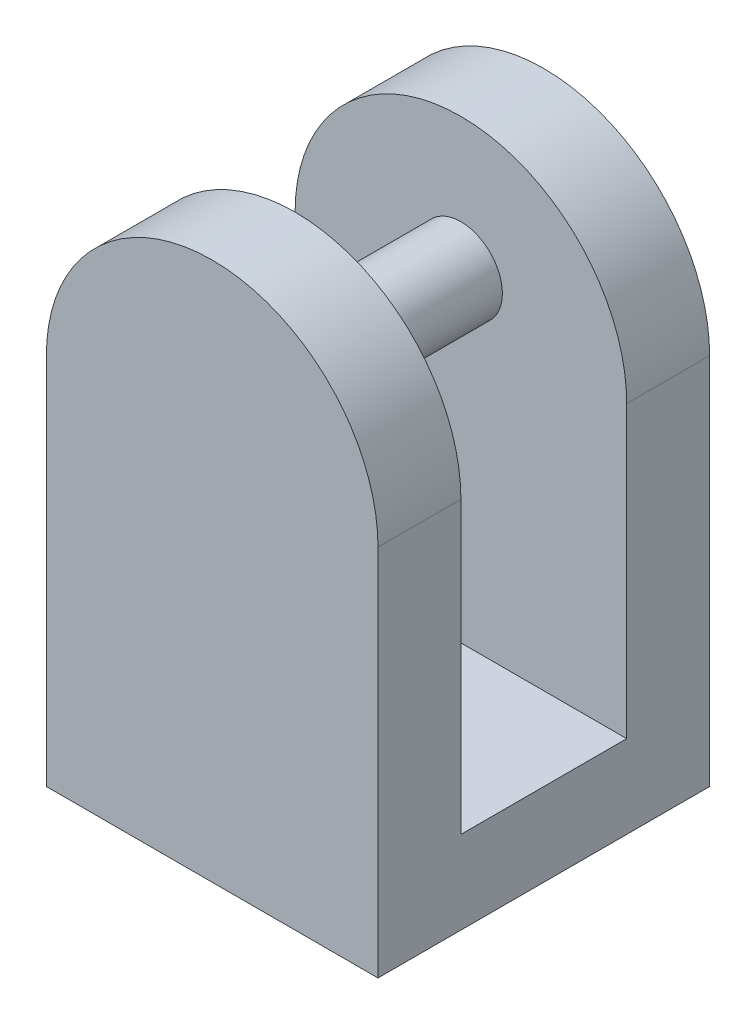
from build123d import *

# Parameters (mm, degrees)
BOSS_EXTRUDE1_DEPTH = 10
SKETCH3_W           = 20
SKETCH3_H           = 10
CUT_EXTRUDE2_DEPTH  = 27.5
SKETCH4_R           = 2.5
BOSS_EXTRUDE2_DEPTH = 10
SKETCH5_R           = 1.25
CUT_EXTRUDE4_DEPTH  = 10
SKETCH6_R           = 2.5
CUT_EXTRUDE5_DEPTH  = 1.25


with BuildPart() as part:
    # Sketch1 → Boss-Extrude1 (new body, symmetric)
    with BuildSketch(Plane.XY):
        with BuildLine():
            Line((-10, 22.5), (-10, 0))
            Line((-10, 0), (10, 0))
            Line((10, 0), (10, 22.5))
            ThreePointArc((10, 22.5), (0, 32.5), (-10, 22.5))
        make_face()
    extrude(amount=BOSS_EXTRUDE1_DEPTH, both=True)

    # Sketch3 → Cut-Extrude2 (cut)
    with BuildSketch(Plane(origin=(0, 32.5, 0), x_dir=(1, 0, 0), z_dir=(0, 1, 0))):
        Rectangle(SKETCH3_W, SKETCH3_H)
    extrude(amount=-CUT_EXTRUDE2_DEPTH, mode=Mode.SUBTRACT)

    # Sketch4 → Boss-Extrude2 (add)
    with BuildSketch(Plane(origin=(0, 0, 5), x_dir=(-1, 0, 0), z_dir=(0, 0, -1))):
        with Locations((0, 24.5)):
            Circle(SKETCH4_R)
    extrude(amount=BOSS_EXTRUDE2_DEPTH)

    # Sketch5 → Cut-Extrude4 (cut)
    with BuildSketch(Plane(origin=(0, 5, 0), x_dir=(1, 0, 0), z_dir=(0, 1, 0))):
        Circle(SKETCH5_R)
    extrude(amount=-CUT_EXTRUDE4_DEPTH, mode=Mode.SUBTRACT)

    # Sketch6 → Cut-Extrude5 (cut)
    with BuildSketch(Plane(origin=(0, 5, 0), x_dir=(1, 0, 0), z_dir=(0, 1, 0))):
        Circle(SKETCH6_R)
    extrude(amount=-CUT_EXTRUDE5_DEPTH, mode=Mode.SUBTRACT)


solid = part.part
